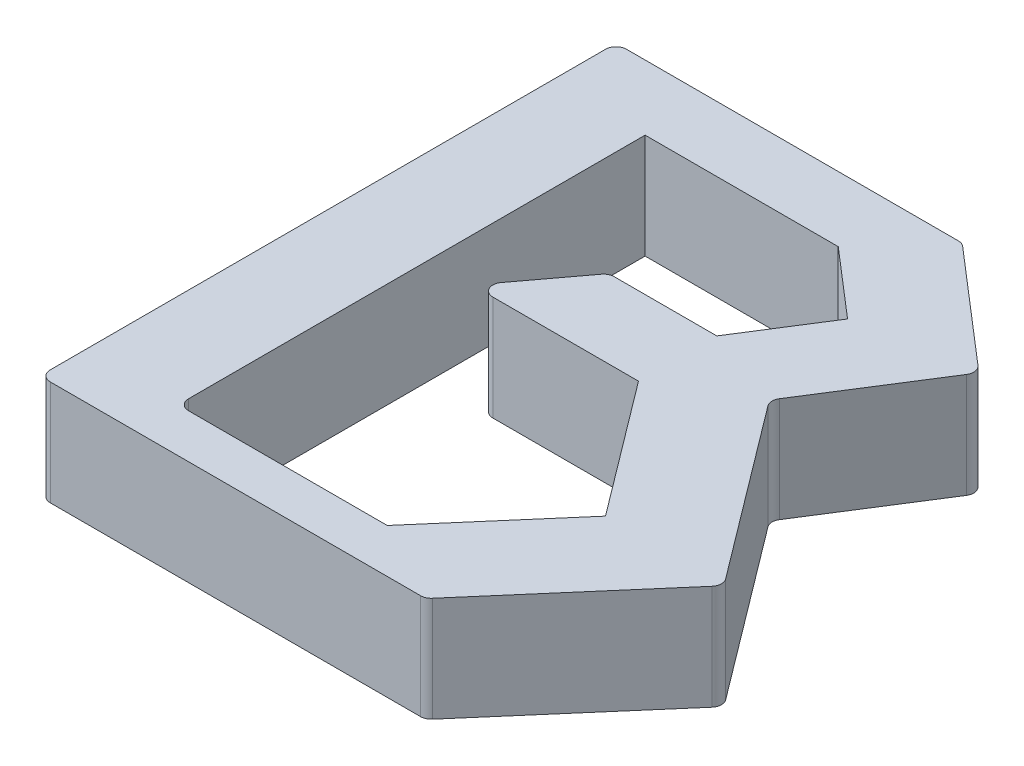
from build123d import *

# Parameters (mm, degrees)
BOSS_EXTRUDE1_DEPTH = 10
FILLET1_R           = 1


with BuildPart() as part:
    # Sketch1 → Boss-Extrude1 (new body)
    with BuildSketch(Plane(origin=(0, 0, 0), x_dir=(1, 0, 0), z_dir=(0, 1, 0))):
        Polygon((33.044354839, 55), (44.567912368, 45.070610508), (36.814516129, 32.822580645), (50, 15.302419355), (36.814516129, 0), (0, 0), (0, 55), align=None)
        Polygon((8.987912628, 48.788514125), (8.987912628, 4.213709677), (28.947590047, 4.213709677), (38.589466872, 15.403594249), (29.007221014, 28.135966803), (13.109814871, 28.135966803), (18.704963548, 35.611652929), (29.007221014, 35.611652929), (33.844976201, 43.25384845), (27.421717413, 48.788514125), align=None, mode=Mode.SUBTRACT)
    extrude(amount=BOSS_EXTRUDE1_DEPTH)

    # Fillet1
    fillet1_edges = [part.edges().sort_by_distance(p)[0] for p in [
        (0, 5, -55),
        (33.044354839, 5, -55),
        (44.567912368, 5, -45.070610508),
        (36.814516129, 5, -32.822580645),
        (50, 5, -15.302419355),
        (36.814516129, 5, 0),
        (0, 5, 0),
        (8.987912628, 5, -4.213709677),
        (13.109814871, 5, -28.135966803),
        (18.704963548, 5, -35.611652929),
    ]]
    fillet(fillet1_edges, radius=FILLET1_R)


solid = part.part
